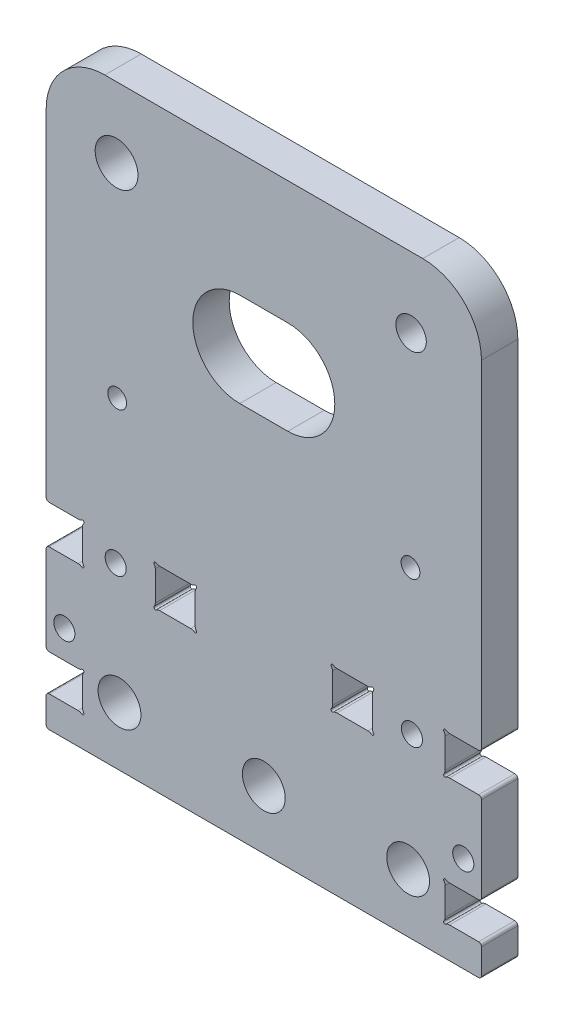
from build123d import *

# Parameters (mm, degrees)
SKETCH1_R           = 3.65
SKETCH1_R_2         = 1.8
SKETCH1_W           = 6.8
SKETCH1_H           = 6.56
SKETCH1_R_3         = 1.6
SKETCH1_R_4         = 2.6
BOSS_EXTRUDE1_DEPTH = 6.2
CUT_EXTRUDE1_DEPTH  = 7.2
SKETCH3_R           = 0.25
CUT_EXTRUDE2_DEPTH  = 7.2
FILLET1_R           = 1
FILLET2_R           = 0.5


with BuildPart() as part:
    # Sketch1 → Boss-Extrude1 (new body)
    with BuildSketch(Plane.XY):
        with BuildLine():
            Line((0, 5.3), (0, 0))
            Line((0, 0), (74.2, 0))
            Line((74.2, 0), (74.2, 5.3))
            Line((74.2, 5.3), (68, 5.3))
            Line((68, 5.3), (68, 11.5))
            Line((68, 11.5), (74.2, 11.5))
            Line((74.2, 11.5), (74.2, 27))
            Line((74.2, 27), (68, 27))
            Line((68, 27), (68, 33.56))
            Line((68, 33.56), (74.2, 33.56))
            Line((74.2, 33.56), (74.2, 91.4))
            ThreePointArc((74.2, 91.4), (71.271067812, 98.471067812), (64.2, 101.4))
            Line((64.2, 101.4), (10, 101.4))
            ThreePointArc((10, 101.4), (2.928932188, 98.471067812), (0, 91.4))
            Line((0, 91.4), (0, 33.56))
            Line((0, 33.56), (6.2, 33.56))
            Line((6.2, 33.56), (6.2, 27))
            Line((6.2, 27), (0, 27))
            Line((0, 27), (0, 11.5))
            Line((0, 11.5), (6.2, 11.5))
            Line((6.2, 11.5), (6.2, 5.3))
            Line((6.2, 5.3), (0, 5.3))
        make_face()
        with Locations((12.5, 10)):
            Circle(SKETCH1_R, mode=Mode.SUBTRACT)
        with Locations((3.1, 16.28)):
            Circle(SKETCH1_R_2, mode=Mode.SUBTRACT)
        with Locations((11.85, 30.28)):
            Circle(SKETCH1_R_2, mode=Mode.SUBTRACT)
        with Locations((22, 30.28)):
            Rectangle(SKETCH1_W, SKETCH1_H, mode=Mode.SUBTRACT)
        with Locations((37.1, 10)):
            Circle(SKETCH1_R, mode=Mode.SUBTRACT)
        with Locations((61.7, 10)):
            Circle(SKETCH1_R, mode=Mode.SUBTRACT)
        with Locations((71.1, 16.28)):
            Circle(SKETCH1_R_2, mode=Mode.SUBTRACT)
        with Locations((52.2, 30.28)):
            Rectangle(SKETCH1_W, SKETCH1_H, mode=Mode.SUBTRACT)
        with Locations((62.35, 30.28)):
            Circle(SKETCH1_R_2, mode=Mode.SUBTRACT)
        with Locations((12.1, 54.75)):
            Circle(SKETCH1_R_3, mode=Mode.SUBTRACT)
        with Locations((12, 89.4)):
            Circle(SKETCH1_R, mode=Mode.SUBTRACT)
        with Locations((62.1, 54.75)):
            Circle(SKETCH1_R_3, mode=Mode.SUBTRACT)
        with Locations((62.2, 89.4)):
            Circle(SKETCH1_R_4, mode=Mode.SUBTRACT)
    extrude(amount=BOSS_EXTRUDE1_DEPTH)

    # Sketch2 → Cut-Extrude1 (cut, through all)
    with BuildSketch(Plane.XY.offset(6.2)):
        with BuildLine():
            Line((33, 80.4), (41.2, 80.4))
            ThreePointArc((41.2, 80.4), (49.2, 72.4), (41.2, 64.4))
            Line((41.2, 64.4), (33, 64.4))
            ThreePointArc((33, 64.4), (25, 72.4), (33, 80.4))
        make_face()
    extrude(amount=-CUT_EXTRUDE1_DEPTH, mode=Mode.SUBTRACT)

    # Sketch3 → Cut-Extrude2 (cut, through all)
    with BuildSketch(Plane.XY.offset(6.2)):
        with Locations((6.2, 33.56)):
            Circle(SKETCH3_R)
        with Locations((6.2, 27)):
            Circle(SKETCH3_R)
        with Locations((6.2, 11.5)):
            Circle(SKETCH3_R)
        with Locations((6.2, 5.3)):
            Circle(SKETCH3_R)
        with Locations((25.4, 27)):
            Circle(SKETCH3_R)
        with Locations((18.6, 27)):
            Circle(SKETCH3_R)
        with Locations((18.6, 33.56)):
            Circle(SKETCH3_R)
        with Locations((25.4, 33.56)):
            Circle(SKETCH3_R)
        with Locations((48.8, 33.56)):
            Circle(SKETCH3_R)
        with Locations((48.8, 27)):
            Circle(SKETCH3_R)
        with Locations((55.6, 33.56)):
            Circle(SKETCH3_R)
        with Locations((55.6, 27)):
            Circle(SKETCH3_R)
        with Locations((68, 33.56)):
            Circle(SKETCH3_R)
        with Locations((68, 27)):
            Circle(SKETCH3_R)
        with Locations((68, 11.5)):
            Circle(SKETCH3_R)
        with Locations((68, 5.3)):
            Circle(SKETCH3_R)
    extrude(amount=-CUT_EXTRUDE2_DEPTH, mode=Mode.SUBTRACT)

    # Fillet1
    fillet1_edges = [part.edges().sort_by_distance(p)[0] for p in [
        (5.95, 33.56, 3.1),
        (6.2, 33.31, 3.1),
        (6.2, 27.25, 3.1),
        (5.95, 27, 3.1),
        (5.95, 11.5, 3.1),
        (6.2, 11.25, 3.1),
        (6.2, 5.55, 3.1),
        (5.95, 5.3, 3.1),
        (25.4, 27.25, 3.1),
        (25.15, 27, 3.1),
        (18.85, 27, 3.1),
        (18.6, 27.25, 3.1),
        (18.85, 33.56, 3.1),
        (18.6, 33.31, 3.1),
        (25.15, 33.56, 3.1),
        (25.4, 33.31, 3.1),
        (49.05, 33.56, 3.1),
        (48.8, 33.31, 3.1),
        (49.05, 27, 3.1),
        (48.8, 27.25, 3.1),
        (55.35, 33.56, 3.1),
        (55.6, 33.31, 3.1),
        (55.6, 27.25, 3.1),
        (55.35, 27, 3.1),
        (68, 33.31, 3.1),
        (68.25, 33.56, 3.1),
        (68.25, 27, 3.1),
        (68, 27.25, 3.1),
        (68, 11.25, 3.1),
        (68.25, 11.5, 3.1),
        (68.25, 5.3, 3.1),
        (68, 5.55, 3.1),
    ]]
    fillet(fillet1_edges, radius=FILLET1_R)

    # Fillet2
    fillet2_edges = [part.edges().sort_by_distance(p)[0] for p in [
        (74.2, 33.56, 3.1),
        (74.2, 27, 3.1),
        (74.2, 11.5, 3.1),
        (74.2, 5.3, 3.1),
        (74.2, 0, 3.1),
        (0, 0, 3.1),
        (0, 5.3, 3.1),
        (0, 11.5, 3.1),
        (0, 27, 3.1),
        (0, 33.56, 3.1),
    ]]
    fillet(fillet2_edges, radius=FILLET2_R)


solid = part.part
